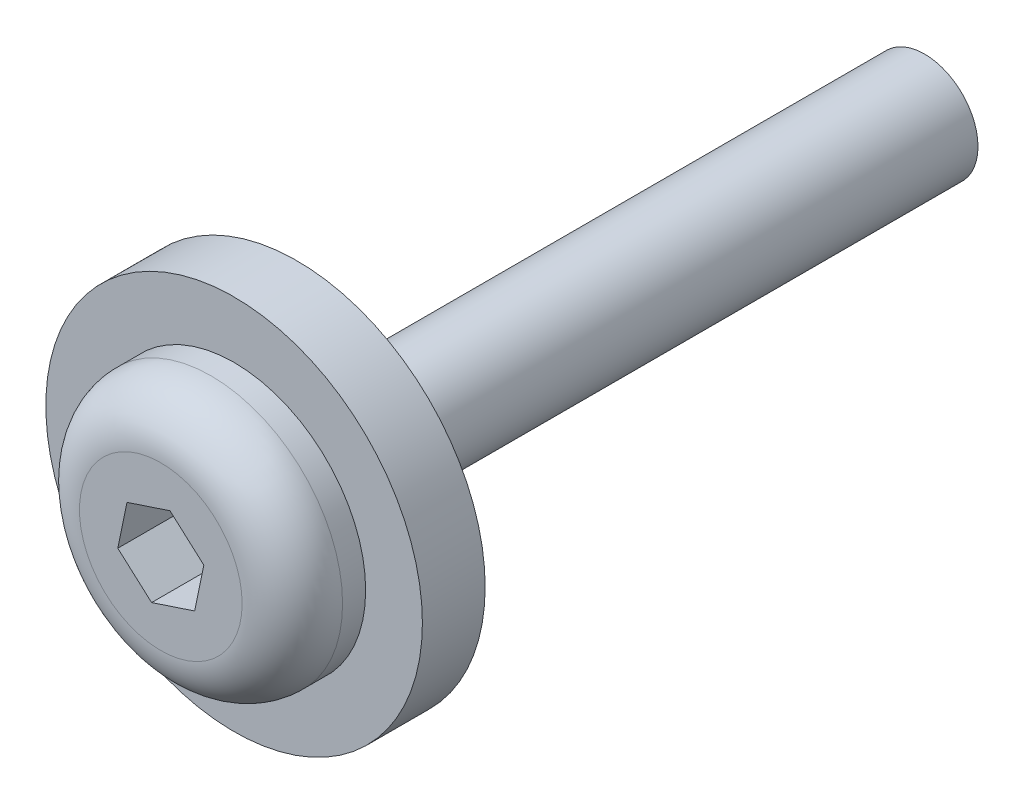
from build123d import *

# Parameters (mm, degrees)
SKETCH1_R           = 1.35255
BOSS_EXTRUDE1_DEPTH = 15.875
SKETCH2_R           = 4.7625
BOSS_EXTRUDE2_DEPTH = 1.5875
SKETCH3_R           = 3.3274
BOSS_EXTRUDE3_DEPTH = 1.8542
FILLET1_R           = 1.27
CUT_EXTRUDE1_DEPTH  = 1.8542


with BuildPart() as part:
    # Sketch1 → Boss-Extrude1 (new body)
    with BuildSketch(Plane.XY):
        Circle(SKETCH1_R)
    extrude(amount=BOSS_EXTRUDE1_DEPTH)

    # Sketch2 → Boss-Extrude2 (add)
    with BuildSketch(Plane.XY.offset(15.875)):
        Circle(SKETCH2_R)
    extrude(amount=BOSS_EXTRUDE2_DEPTH)

    # Sketch3 → Boss-Extrude3 (add)
    with BuildSketch(Plane.XY.offset(17.4625)):
        Circle(SKETCH3_R)
    extrude(amount=BOSS_EXTRUDE3_DEPTH)

    # Fillet1
    fillet1_edges = [part.edges().sort_by_distance(p)[0] for p in [
        (-3.3274, 0, 19.3167),
    ]]
    fillet(fillet1_edges, radius=FILLET1_R)

    # Sketch4 → Cut-Extrude1 (cut)
    with BuildSketch(Plane.XY.offset(19.3167)):
        Polygon((1.087800583, 0.359543143), (0.232526796, 1.121834511), (-0.855273787, 0.762291368), (-1.087800583, -0.359543143), (-0.232526796, -1.121834511), (0.855273787, -0.762291368), align=None)
    extrude(amount=-CUT_EXTRUDE1_DEPTH, mode=Mode.SUBTRACT)


solid = part.part
